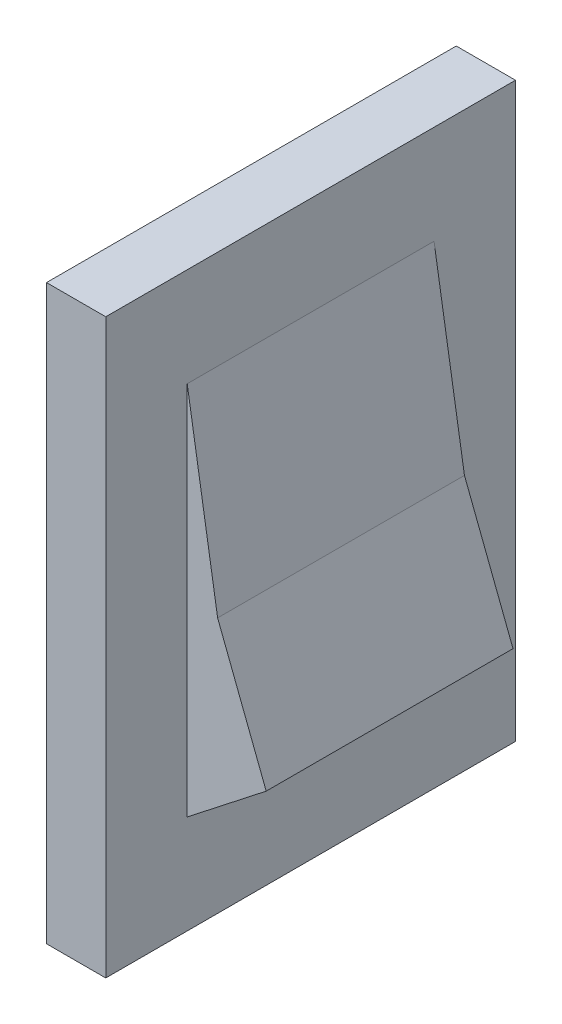
from build123d import *

# Parameters (mm, degrees)
SKETCH1_W           = 10.541
SKETCH1_H           = 14.732
BOSS_EXTRUDE1_DEPTH = 1.524
SKETCH2_W           = 6.35
SKETCH2_H           = 9.652
BOSS_EXTRUDE2_DEPTH = 2.032
CUT_EXTRUDE1_DEPTH  = 6.35


with BuildPart() as part:
    # Sketch1 → Boss-Extrude1 (new body)
    with BuildSketch(Plane(origin=(0, 0, 0), x_dir=(0, 0, -1), z_dir=(1, 0, 0))):
        Rectangle(SKETCH1_W, SKETCH1_H)
    extrude(amount=BOSS_EXTRUDE1_DEPTH)

    # Sketch2 → Boss-Extrude2 (add)
    with BuildSketch(Plane(origin=(1.524, 0, 0), x_dir=(0, 0, -1), z_dir=(1, 0, 0))):
        Rectangle(SKETCH2_W, SKETCH2_H)
    extrude(amount=BOSS_EXTRUDE2_DEPTH)

    # Sketch3 → Cut-Extrude1 (cut)
    with BuildSketch(Plane.XY.offset(3.175)):
        Polygon((1.524, -4.826), (3.556, -3.234816243), (2.306647012, 0), (1.524, 4.826), (4.824013739, 4.826), (4.824013739, -4.826), align=None)
    extrude(amount=-CUT_EXTRUDE1_DEPTH, mode=Mode.SUBTRACT)


solid = part.part
